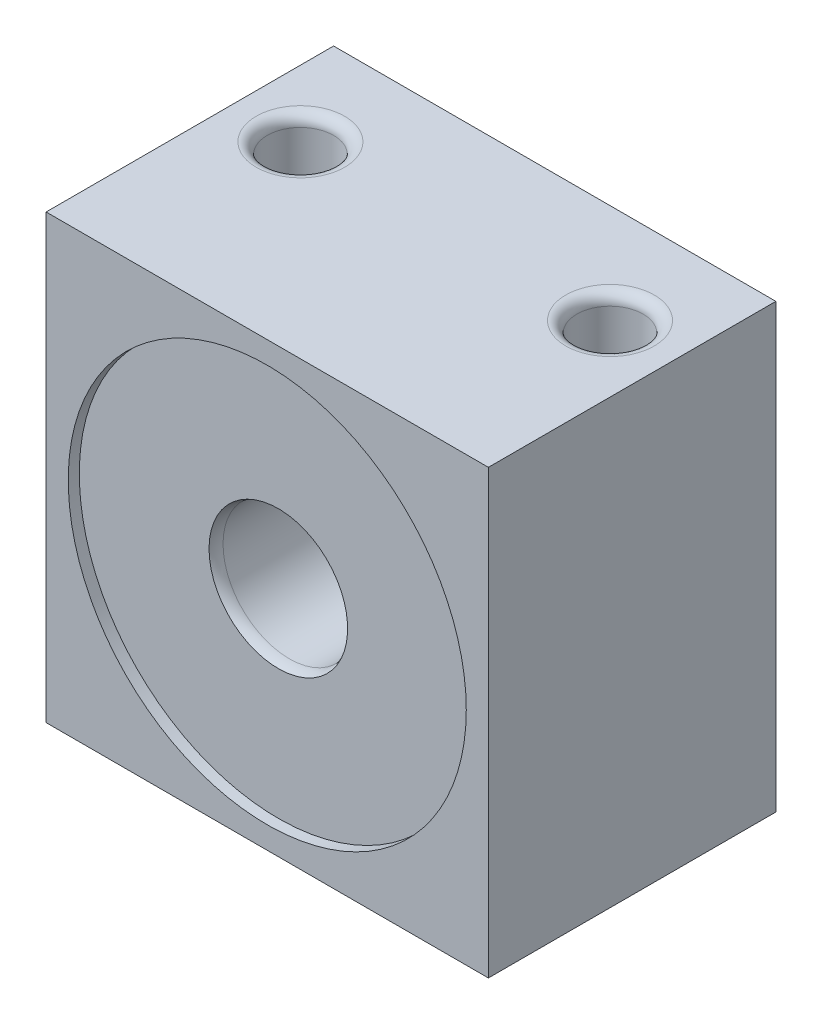
from build123d import *

# Parameters (mm, degrees)
ESQUISSE1_W             = 20
ESQUISSE1_H             = 13
BOSS_EXTRU_1_DEPTH      = 20
ESQUISSE2_R             = 3
ENL_V_MAT_EXTRU_1_DEPTH = 20
ESQUISSE3_R             = 1.5
ENL_V_MAT_EXTRU_2_DEPTH = 20
CONG_1_R                = 1
CONG_2_R                = 0.5
CONG_3_R                = 0.5
CONG_4_R                = 0.5
CONG_5_R                = 0.5
CONG_6_R                = 1
ESQUISSE4_R             = 9
ESQUISSE4_R_2           = 3
ENL_V_MAT_EXTRU_3_DEPTH = 0.5


with BuildPart() as part:
    # Esquisse1 → Boss.-Extru.1 (new body)
    with BuildSketch(Plane(origin=(0, 0, 0), x_dir=(1, 0, 0), z_dir=(0, 1, 0))):
        Rectangle(ESQUISSE1_W, ESQUISSE1_H)
    extrude(amount=BOSS_EXTRU_1_DEPTH)

    # Esquisse2 → Enlèv. mat.-Extru.1 (cut)
    with BuildSketch(Plane.XY.offset(6.5)):
        with Locations((0, 10)):
            Circle(ESQUISSE2_R)
    extrude(amount=-ENL_V_MAT_EXTRU_1_DEPTH, mode=Mode.SUBTRACT)

    # Esquisse3 → Enlèv. mat.-Extru.2 (cut)
    with BuildSketch(Plane(origin=(0, 20, 0), x_dir=(1, 0, 0), z_dir=(0, 1, 0))):
        with Locations((-7, 2)):
            Circle(ESQUISSE3_R)
        with Locations((7, 2)):
            Circle(ESQUISSE3_R)
    extrude(amount=-ENL_V_MAT_EXTRU_2_DEPTH, mode=Mode.SUBTRACT)

    # Congé1
    cong_1_edges = [part.edges().sort_by_distance(p)[0] for p in [
        (-3, 10, 6.5),
    ]]
    fillet(cong_1_edges, radius=CONG_1_R)

    # Congé2
    cong_2_edges = [part.edges().sort_by_distance(p)[0] for p in [
        (-8.5, 20, -2),
    ]]
    fillet(cong_2_edges, radius=CONG_2_R)

    # Congé3
    cong_3_edges = [part.edges().sort_by_distance(p)[0] for p in [
        (5.5, 20, -2),
    ]]
    fillet(cong_3_edges, radius=CONG_3_R)

    # Congé4
    cong_4_edges = [part.edges().sort_by_distance(p)[0] for p in [
        (-8.5, 0, -2),
    ]]
    fillet(cong_4_edges, radius=CONG_4_R)

    # Congé5
    cong_5_edges = [part.edges().sort_by_distance(p)[0] for p in [
        (5.5, 0, -2),
    ]]
    fillet(cong_5_edges, radius=CONG_5_R)

    # Congé6
    cong_6_edges = [part.edges().sort_by_distance(p)[0] for p in [
        (-3, 10, -6.5),
    ]]
    fillet(cong_6_edges, radius=CONG_6_R)

    # Esquisse4 → Enlèv. mat.-Extru.3 (cut)
    with BuildSketch(Plane.XY.offset(6.5)):
        with Locations((0, 10)):
            Circle(ESQUISSE4_R)
        with Locations((0, 10)):
            Circle(ESQUISSE4_R_2, mode=Mode.SUBTRACT)
    enl_v_mat_extru_3 = extrude(amount=-ENL_V_MAT_EXTRU_3_DEPTH, mode=Mode.SUBTRACT)

    # Symétrie1: Enlèv. mat.-Extru.3 across plane
    add(enl_v_mat_extru_3.mirror(Plane.XY), mode=Mode.SUBTRACT)


solid = part.part
